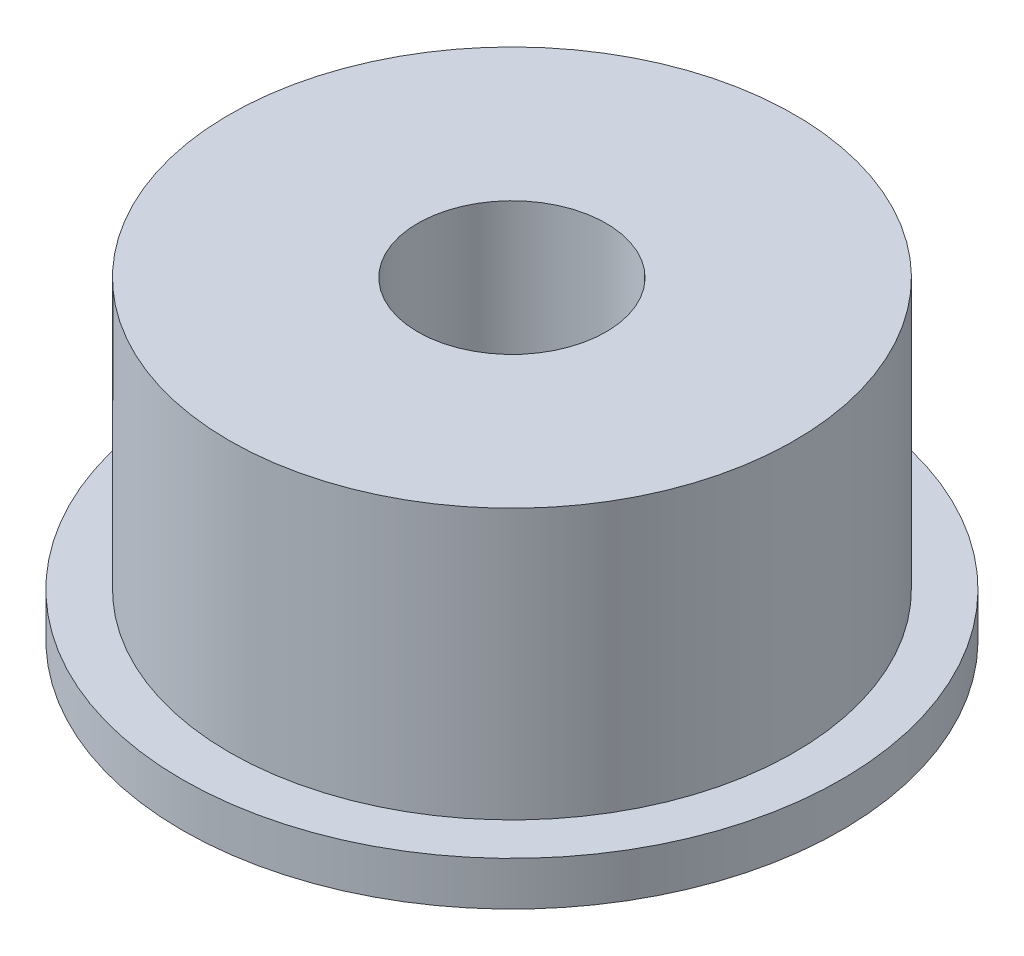
from build123d import *

# Parameters (mm, degrees)
SKETCH_1_R          = 5.25
EXTRUDE_1_DEPTH     = 0.7
SKETCH_2_R          = 4.5
EXTRUDE_2_DEPTH     = 4.3
SKETCH_3_R          = 1.5
CUT_EXTRUDE_1_DEPTH = 6


with BuildPart() as part:
    # 草图1 → 凸台-拉伸1 (new body)
    with BuildSketch(Plane(origin=(0, 0, 0), x_dir=(1, 0, 0), z_dir=(0, 1, 0))):
        Circle(SKETCH_1_R)
    extrude(amount=EXTRUDE_1_DEPTH)

    # 草图2 → 凸台-拉伸2 (add)
    with BuildSketch(Plane(origin=(0, 0.7, 0), x_dir=(1, 0, 0), z_dir=(0, 1, 0))):
        Circle(SKETCH_2_R)
    extrude(amount=EXTRUDE_2_DEPTH)

    # 草图3 → 切除-拉伸1 (cut, through all)
    with BuildSketch(Plane(origin=(0, 5, 0), x_dir=(1, 0, 0), z_dir=(0, 1, 0))):
        Circle(SKETCH_3_R)
    extrude(amount=-CUT_EXTRUDE_1_DEPTH, mode=Mode.SUBTRACT)


solid = part.part
